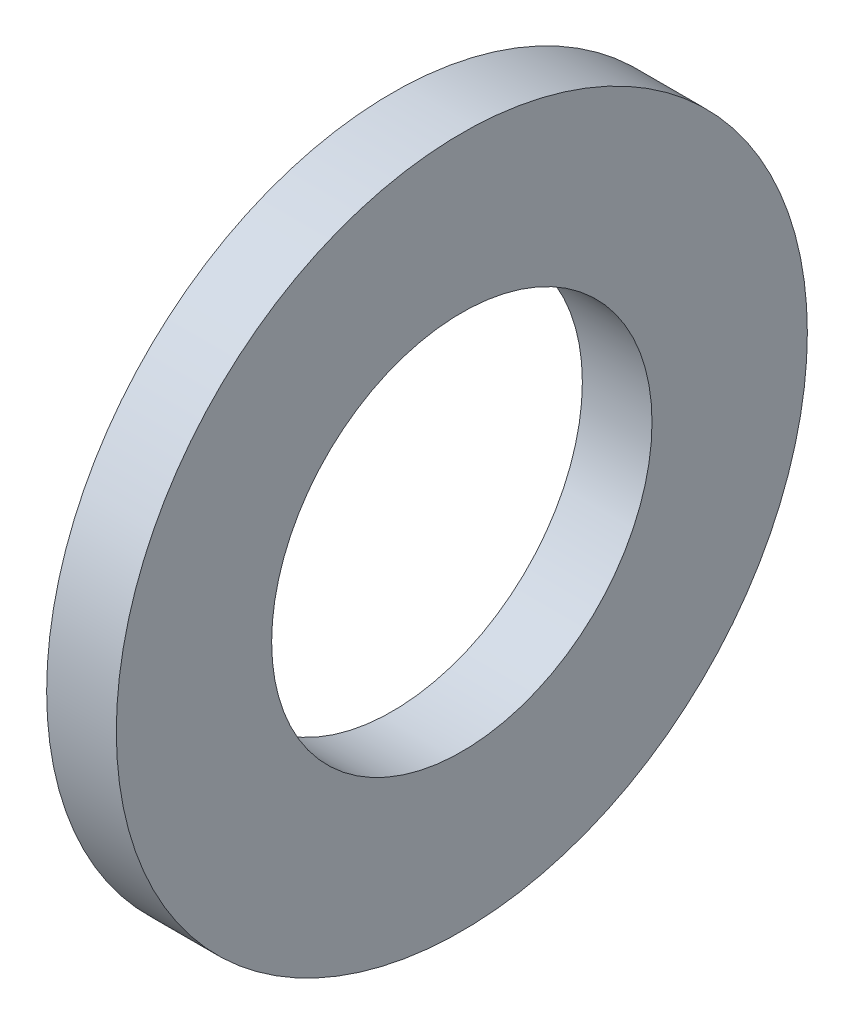
from build123d import *

# Parameters (mm, degrees)
SKETCH1_W = 1.6002
SKETCH1_H = 3.5687


with BuildPart() as part:
    # Sketch1 → Base-Revolve (revolve)
    with BuildSketch(Plane.XY):
        with Locations((-0.8001, 6.15315)):
            Rectangle(SKETCH1_W, SKETCH1_H)
    revolve(axis=Axis((-34.925, 0, 0), (1, 0, 0)))


solid = part.part
